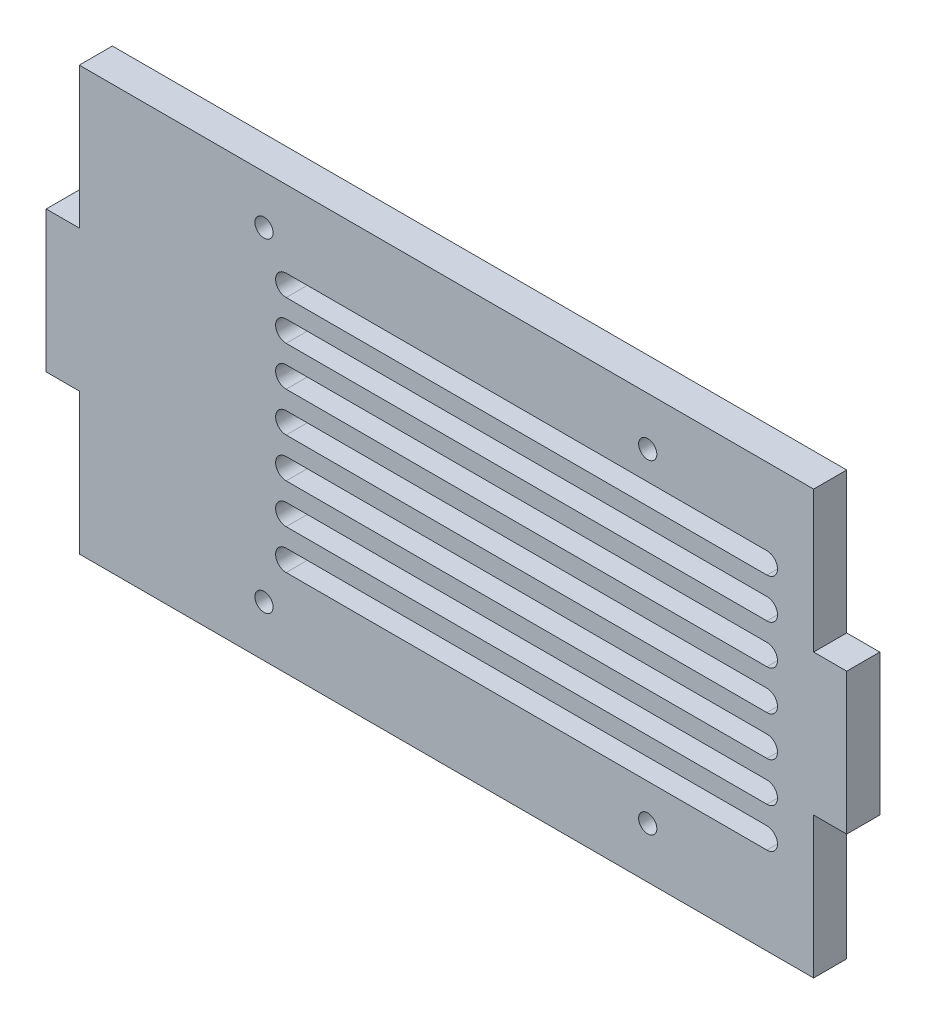
from build123d import *

# Parameters (mm, degrees)
CROQUIS1_W              = 111
CROQUIS1_H              = 64
CROQUIS1_R              = 1.375
SALIENTE_EXTRUIR1_DEPTH = 5
CROQUIS2_W              = 5
CROQUIS2_H              = 21.333333334
SALIENTE_EXTRUIR2_DEPTH = 5
CROQUIS3_W              = 5
CROQUIS3_H              = 21.333333334
SALIENTE_EXTRUIR3_DEPTH = 5


with BuildPart() as part:
    # Croquis1 → Saliente-Extruir1 (new body)
    with BuildSketch(Plane.XY):
        with Locations((12.5, -8)):
            Rectangle(CROQUIS1_W, CROQUIS1_H)
        with Locations((42.920083817, -32.303397977)):
            Circle(CROQUIS1_R, mode=Mode.SUBTRACT)
        with Locations((42.920083817, 16.696602023)):
            Circle(CROQUIS1_R, mode=Mode.SUBTRACT)
        with Locations((-15.079916183, -32.303397977)):
            Circle(CROQUIS1_R, mode=Mode.SUBTRACT)
        with Locations((-15.079916183, 16.696602023)):
            Circle(CROQUIS1_R, mode=Mode.SUBTRACT)
        with BuildLine():
            Line((60.939336221, 9.212655439), (-11.729916183, 9.212655439))
            ThreePointArc((-11.729916183, 9.212655439), (-13.325171123, 10.807910378), (-11.729916183, 12.403165318))
            Line((-11.729916183, 12.403165318), (60.939336221, 12.403165318))
            ThreePointArc((60.939336221, 12.403165318), (62.53459116, 10.807910378), (60.939336221, 9.212655439))
        make_face(mode=Mode.SUBTRACT)
        with BuildLine():
            Line((60.939336221, 3.212655439), (-11.729916183, 3.212655439))
            ThreePointArc((-11.729916183, 3.212655439), (-13.325171123, 4.807910378), (-11.729916183, 6.403165318))
            Line((-11.729916183, 6.403165318), (60.939336221, 6.403165318))
            ThreePointArc((60.939336221, 6.403165318), (62.53459116, 4.807910378), (60.939336221, 3.212655439))
        make_face(mode=Mode.SUBTRACT)
        with BuildLine():
            Line((60.939336221, -2.787344561), (-11.729916183, -2.787344561))
            ThreePointArc((-11.729916183, -2.787344561), (-13.325171123, -1.192089622), (-11.729916183, 0.403165318))
            Line((-11.729916183, 0.403165318), (60.939336221, 0.403165318))
            ThreePointArc((60.939336221, 0.403165318), (62.53459116, -1.192089622), (60.939336221, -2.787344561))
        make_face(mode=Mode.SUBTRACT)
        with BuildLine():
            Line((60.939336221, -8.787344561), (-11.729916183, -8.787344561))
            ThreePointArc((-11.729916183, -8.787344561), (-13.325171123, -7.192089622), (-11.729916183, -5.596834682))
            Line((-11.729916183, -5.596834682), (60.939336221, -5.596834682))
            ThreePointArc((60.939336221, -5.596834682), (62.53459116, -7.192089622), (60.939336221, -8.787344561))
        make_face(mode=Mode.SUBTRACT)
        with BuildLine():
            Line((60.939336221, -14.787344561), (-11.729916183, -14.787344561))
            ThreePointArc((-11.729916183, -14.787344561), (-13.325171123, -13.192089622), (-11.729916183, -11.596834682))
            Line((-11.729916183, -11.596834682), (60.939336221, -11.596834682))
            ThreePointArc((60.939336221, -11.596834682), (62.53459116, -13.192089622), (60.939336221, -14.787344561))
        make_face(mode=Mode.SUBTRACT)
        with BuildLine():
            Line((60.939336221, -20.787344561), (-11.729916183, -20.787344561))
            ThreePointArc((-11.729916183, -20.787344561), (-13.325171123, -19.192089622), (-11.729916183, -17.596834682))
            Line((-11.729916183, -17.596834682), (60.939336221, -17.596834682))
            ThreePointArc((60.939336221, -17.596834682), (62.53459116, -19.192089622), (60.939336221, -20.787344561))
        make_face(mode=Mode.SUBTRACT)
        with BuildLine():
            Line((60.939336221, -26.787344561), (-11.729916183, -26.787344561))
            ThreePointArc((-11.729916183, -26.787344561), (-13.325171123, -25.192089622), (-11.729916183, -23.596834682))
            Line((-11.729916183, -23.596834682), (60.939336221, -23.596834682))
            ThreePointArc((60.939336221, -23.596834682), (62.53459116, -25.192089622), (60.939336221, -26.787344561))
        make_face(mode=Mode.SUBTRACT)
    extrude(amount=SALIENTE_EXTRUIR1_DEPTH)

    # Croquis2 → Saliente-Extruir2 (add)
    with BuildSketch(Plane(origin=(68, 0, 0), x_dir=(0, 0, -1), z_dir=(1, 0, 0))):
        with Locations((-2.5, -8)):
            Rectangle(CROQUIS2_W, CROQUIS2_H)
    extrude(amount=SALIENTE_EXTRUIR2_DEPTH)

    # Croquis3 → Saliente-Extruir3 (add)
    with BuildSketch(Plane.ZY.offset(43)):
        with Locations((2.5, -8)):
            Rectangle(CROQUIS3_W, CROQUIS3_H)
    extrude(amount=SALIENTE_EXTRUIR3_DEPTH)


solid = part.part
